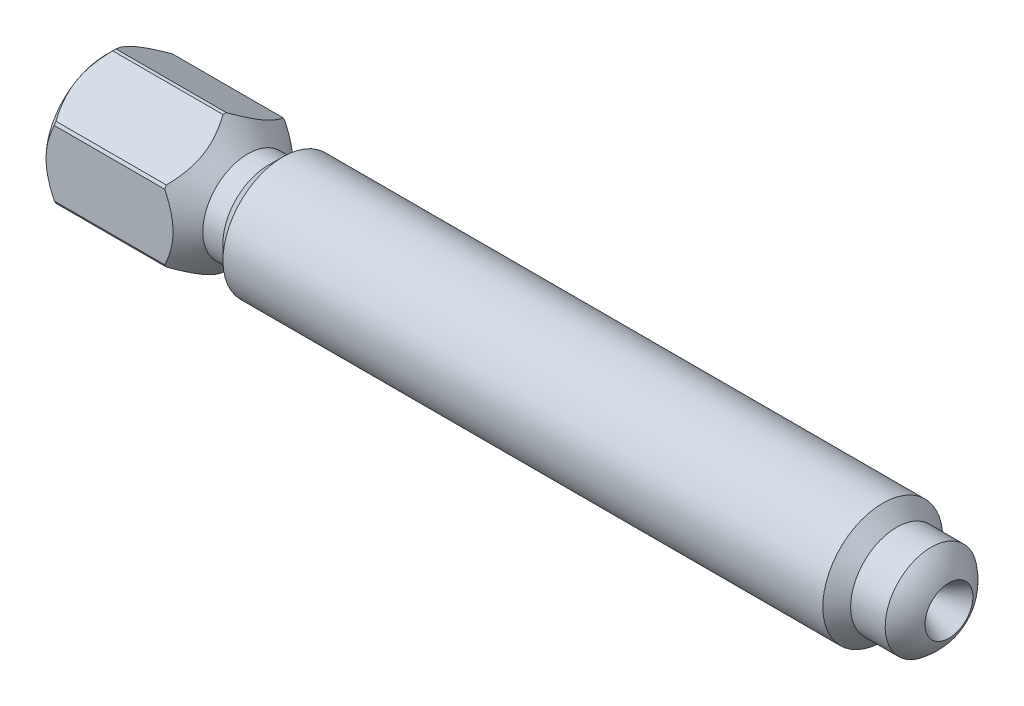
from build123d import *

# Parameters (mm, degrees)
SKETCH2_OUTSIDE_W  = 23.076
SKETCH2_OUTSIDE_H  = 23.077
CUT_EXTRUDE1_DEPTH = 57.16575
SKETCH3_OUTSIDE_W  = 21.43
SKETCH3_OUTSIDE_H  = 22.658
SKETCH3_OUTSIDE_R  = 4.5212
CUT_EXTRUDE2_DEPTH = 57.16575


with BuildPart() as part:
    # Sketch1 → Revolve1 (revolve)
    with BuildSketch(Plane.XY):
        with BuildLine():
            Line((-4.73075, 3.96875), (-44.45, 3.96875))
            Line((-44.45, 3.96875), (-45.43425, 2.9845))
            Line((-45.43425, 2.9845), (-46.76775, 2.9845))
            Line((-46.76775, 2.9845), (-48.54575, 4.7625))
            Line((-48.54575, 4.7625), (-55.372, 4.7625))
            Line((-55.372, 4.7625), (-56.16575, 3.96875))
            Line((-56.16575, 3.96875), (-56.16575, 0))
            Line((-56.16575, 0), (0, 0))
            ThreePointArc((0, 0), (-0.402232402, 1.703883799), (-1.524, 3.048))
            Line((-1.524, 3.048), (-3.81, 3.048))
            Line((-3.81, 3.048), (-4.73075, 3.96875))
        make_face()
    revolve(axis=Axis((1.163601772, 0, 0), (-1, 0, 0)))

    # Sketch2 outside → Cut-Extrude1 (cut, through all)
    with BuildSketch(Plane.ZY.offset(56.16575)):
        with Locations((0, -0.0005)):
            Rectangle(SKETCH2_OUTSIDE_W, SKETCH2_OUTSIDE_H)
        Polygon((0, -4.582717762), (3.96875, -2.291358881), (3.96875, 2.291358881), (0, 4.582717762), (-3.96875, 2.291358881), (-3.96875, -2.291358881), align=None, mode=Mode.SUBTRACT)
    extrude(amount=-CUT_EXTRUDE1_DEPTH, mode=Mode.SUBTRACT)

    # Sketch3 outside → Cut-Extrude2 (cut, through all)
    with BuildSketch(Plane.ZY.offset(56.16575)):
        Rectangle(SKETCH3_OUTSIDE_W, SKETCH3_OUTSIDE_H)
        Circle(SKETCH3_OUTSIDE_R, mode=Mode.SUBTRACT)
    extrude(amount=-CUT_EXTRUDE2_DEPTH, mode=Mode.SUBTRACT)

    # Sketch4 → Cut-Revolve1 (revolve, cut)
    with BuildSketch(Plane.XY):
        with BuildLine():
            Line((-0.346483904, 1.5875), (-2.065003064, 0.5953125))
            Line((-2.065003064, 0.5953125), (-3.255628064, 0.5953125))
            Line((-3.255628064, 0.5953125), (-3.599331896, 0))
            Line((-3.599331896, 0), (0, 0))
            ThreePointArc((0, 0), (-0.087628691, 0.812435743), (-0.346483904, 1.5875))
        make_face()
        Polygon((-56.16575, 0), (-52.912902007, 0), (-53.256605839, 0.5953125), (-54.447230839, 0.5953125), (-56.16575, 1.5875), align=None)
    revolve(axis=Axis((1.163601772, 0, 0), (-1, 0, 0)), mode=Mode.SUBTRACT)


solid = part.part
